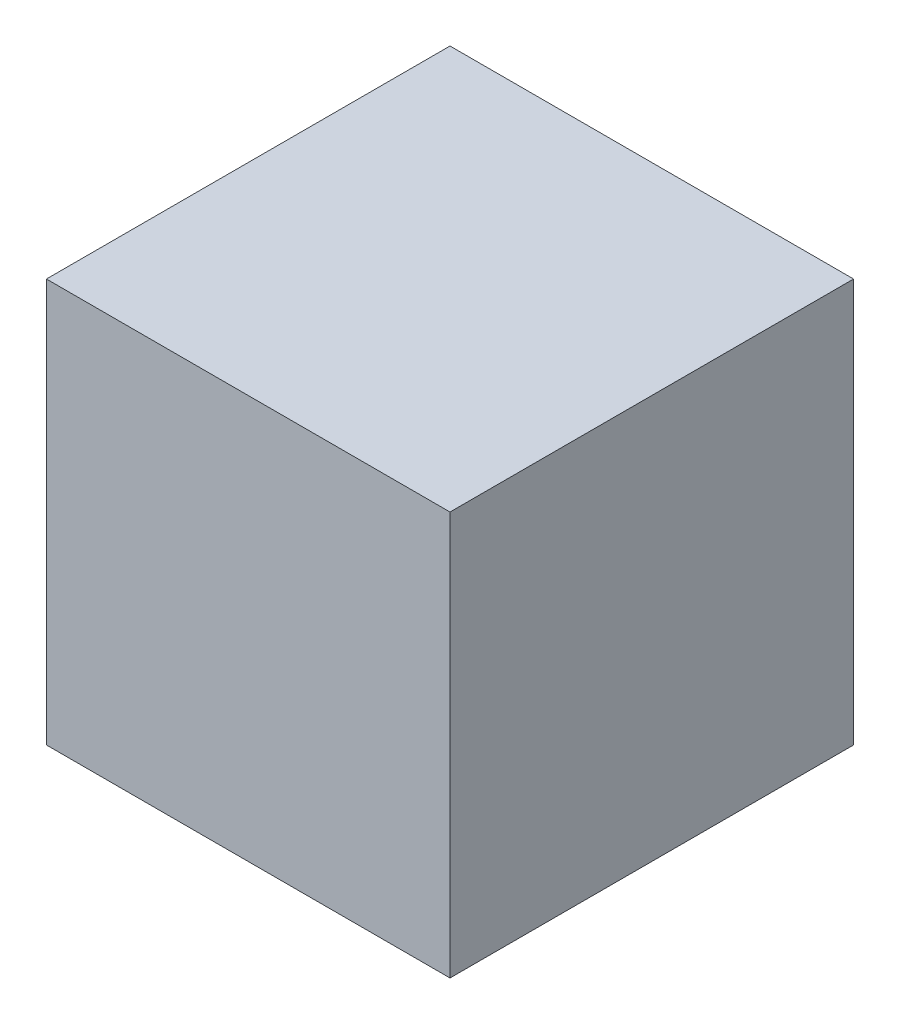
from build123d import *

# Parameters (mm, degrees)
SKETCH_1_W      = 100
SKETCH_1_H      = 100
EXTRUDE_1_DEPTH = 100


with BuildPart() as part:
    # 草图1 → 凸台-拉伸1 (new body)
    with BuildSketch(Plane.XY):
        Rectangle(SKETCH_1_W, SKETCH_1_H)
    extrude(amount=EXTRUDE_1_DEPTH)


solid = part.part
